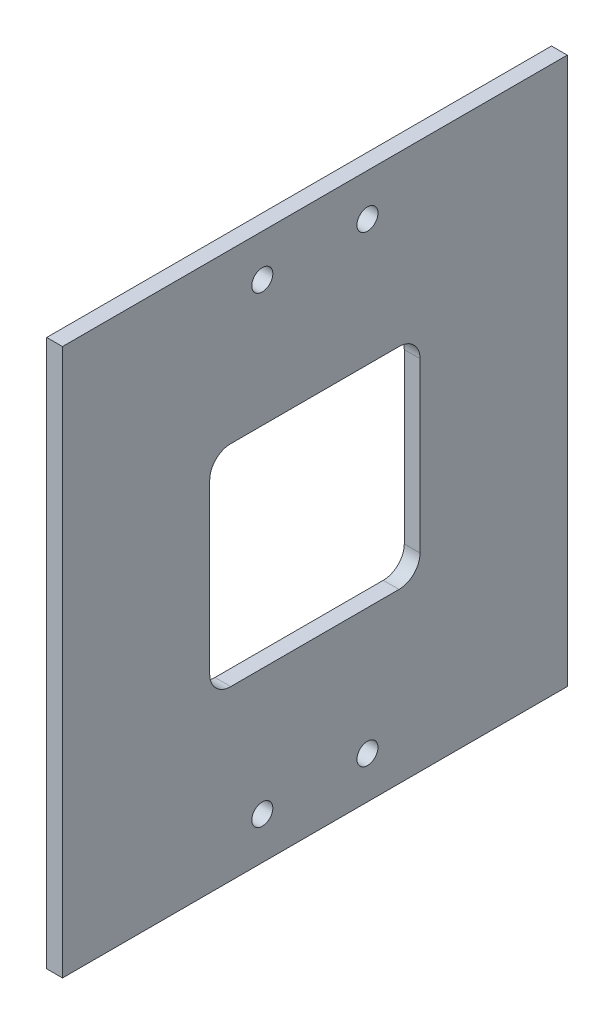
from build123d import *

# Parameters (mm, degrees)
SKETCH1_W           = 152.4
SKETCH1_H           = 165.1
BOSS_EXTRUDE1_DEPTH = 4.7625
CUT_EXTRUDE1_DEPTH  = 5.7625
SKETCH3_R           = 3.175
CUT_EXTRUDE2_DEPTH  = 5.7625


with BuildPart() as part:
    # Sketch1 → Boss-Extrude1 (new body)
    with BuildSketch(Plane(origin=(0, 0, 0), x_dir=(0, 0, -1), z_dir=(1, 0, 0))):
        with Locations((76.2, 0)):
            Rectangle(SKETCH1_W, SKETCH1_H)
    extrude(amount=BOSS_EXTRUDE1_DEPTH)

    # Sketch2 → Cut-Extrude1 (cut, through all)
    with BuildSketch(Plane.ZY):
        with BuildLine():
            Line((-107.95, 25.4), (-107.95, -25.4))
            ThreePointArc((-107.95, -25.4), (-106.090128061, -29.890128061), (-101.6, -31.75))
            Line((-101.6, -31.75), (-50.8, -31.75))
            ThreePointArc((-50.8, -31.75), (-46.309871939, -29.890128061), (-44.45, -25.4))
            Line((-44.45, -25.4), (-44.45, 25.4))
            ThreePointArc((-44.45, 25.4), (-46.309871939, 29.890128061), (-50.8, 31.75))
            Line((-50.8, 31.75), (-101.6, 31.75))
            ThreePointArc((-101.6, 31.75), (-106.090128061, 29.890128061), (-107.95, 25.4))
        make_face()
    extrude(amount=-CUT_EXTRUDE1_DEPTH, mode=Mode.SUBTRACT)

    # Sketch3 → Cut-Extrude2 (cut, through all)
    with BuildSketch(Plane.ZY):
        with Locations((-60.325, 69.85)):
            Circle(SKETCH3_R)
        with Locations((-92.075, 69.85)):
            Circle(SKETCH3_R)
        with Locations((-92.075, -69.85)):
            Circle(SKETCH3_R)
        with Locations((-60.325, -69.85)):
            Circle(SKETCH3_R)
    extrude(amount=-CUT_EXTRUDE2_DEPTH, mode=Mode.SUBTRACT)


solid = part.part
